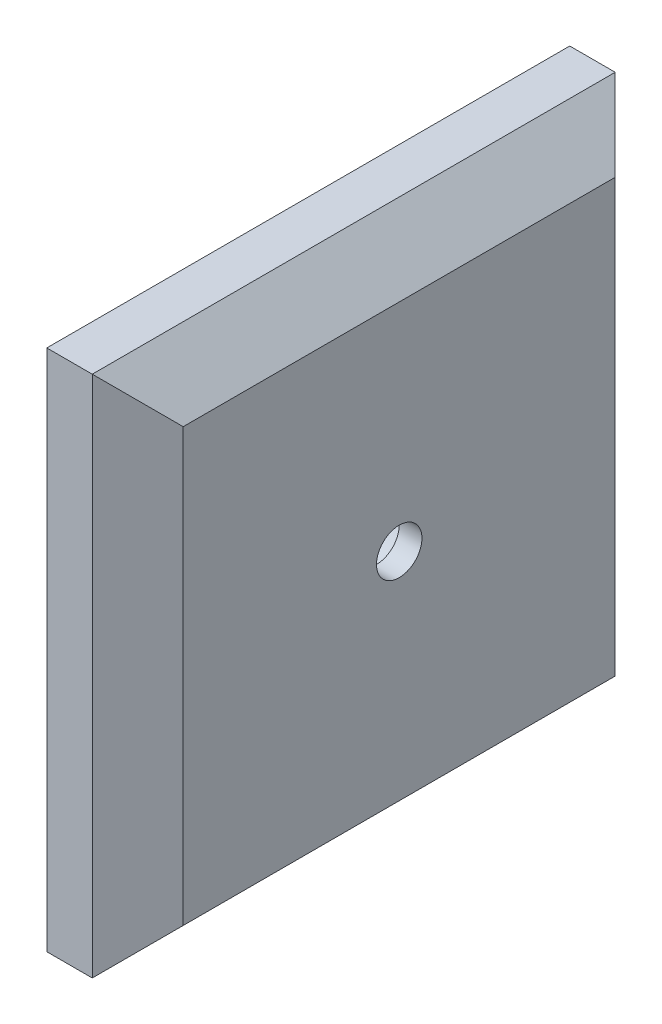
from build123d import *

# Parameters (mm, degrees)
SKETCH2_W           = 73.025
SKETCH2_H           = 73.025
BOSS_EXTRUDE1_DEPTH = 12.7
CHAMFER1_SIZE       = 6.35
SKETCH5_R           = 3.175
CUT_EXTRUDE1_DEPTH  = 3.175
SKETCH6_R           = 6.35
CUT_EXTRUDE2_DEPTH  = 9.525


with BuildPart() as part:
    # Sketch2 → Boss-Extrude1 (new body)
    with BuildSketch(Plane(origin=(0, 0, 0), x_dir=(0, 0, -1), z_dir=(1, 0, 0))):
        Rectangle(SKETCH2_W, SKETCH2_H)
    extrude(amount=BOSS_EXTRUDE1_DEPTH)

    # Chamfer1
    chamfer1_edges = [part.edges().sort_by_distance(p)[0] for p in [
        (12.7, 0, 36.5125),
        (12.7, -36.5125, 0),
        (12.7, 0, -36.5125),
        (12.7, 36.5125, 0),
    ]]
    chamfer(chamfer1_edges, length=CHAMFER1_SIZE)

    # Sketch5 → Cut-Extrude1 (cut)
    with BuildSketch(Plane(origin=(12.7, 0, 0), x_dir=(0, 0, -1), z_dir=(1, 0, 0))):
        Circle(SKETCH5_R)
    extrude(amount=-CUT_EXTRUDE1_DEPTH, mode=Mode.SUBTRACT)

    # Sketch6 → Cut-Extrude2 (cut)
    with BuildSketch(Plane.ZY):
        Circle(SKETCH6_R)
    extrude(amount=-CUT_EXTRUDE2_DEPTH, mode=Mode.SUBTRACT)


solid = part.part
